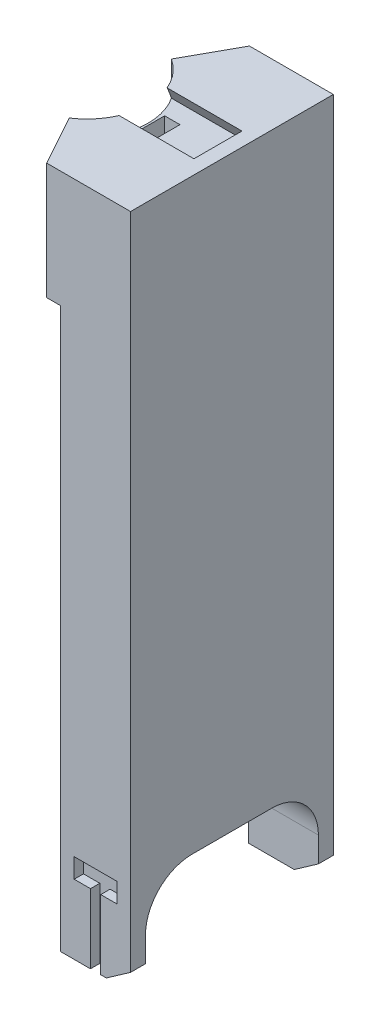
from build123d import *

# Parameters (mm, degrees)
SKETCH2_W               = 18
SKETCH2_H               = 43.5
BOSS_EXTRUDE1_DEPTH     = 25
CUT_EXTRUDE1_DEPTH      = 15
CUT_EXTRUDE1_DEPTH_BACK = 6.951267747
CUT_EXTRUDE2_START      = 0.4
CUT_EXTRUDE2_DEPTH      = 3.3
SKETCH5_W               = 15
SKETCH5_H               = 43.5
BOSS_EXTRUDE2_DEPTH     = 120
SKETCH6_W               = 2.2
SKETCH6_H               = 14.9
CUT_EXTRUDE3_DEPTH      = 2
CUT_EXTRUDE4_START      = -43.5
SKETCH6_3_W             = 2.2
SKETCH6_3_H             = 14.9
CUT_EXTRUDE4_DEPTH      = 2
CUT_EXTRUDE5_DEPTH      = 44.5
SKETCH8_W               = 37.1
SKETCH8_H               = 38
CUT_EXTRUDE6_DEPTH      = 16
FILLET1_R               = 10


with BuildPart() as part:
    # Sketch2 → Boss-Extrude1 (new body)
    with BuildSketch(Plane(origin=(0, 0, 0), x_dir=(1, 0, 0), z_dir=(0, 1, 0))):
        with BuildLine():
            Line((-9, 0), (-9, 21.75))
            Line((-9, 21.75), (-14.951267747, 10.950365309))
            ThreePointArc((-14.951267747, 10.950365309), (-10.583942354, 6.231534486), (-9, 0))
        make_face()
        with BuildLine():
            Line((-9, -21.75), (-9, 0))
            ThreePointArc((-9, 0), (-10.583942354, -6.231534486), (-14.951267747, -10.950365309))
            Line((-14.951267747, -10.950365309), (-9, -21.75))
        make_face()
        Rectangle(SKETCH2_W, SKETCH2_H)
    extrude(amount=BOSS_EXTRUDE1_DEPTH)

    # Sketch3 → Cut-Extrude1 (cut, two sides)
    with BuildSketch(Plane(origin=(-9, 0, 0), x_dir=(0, 0, -1), z_dir=(1, 0, 0))) as cut_extrude1_sk:
        Polygon((-5.15, 25), (5.15, 25), (7.15, 21.535898385), (-7.15, 21.535898385), align=None)
    extrude(amount=CUT_EXTRUDE1_DEPTH, mode=Mode.SUBTRACT)
    extrude(cut_extrude1_sk.sketch, amount=-CUT_EXTRUDE1_DEPTH_BACK, mode=Mode.SUBTRACT)

    # Sketch4 → Cut-Extrude2 (cut)
    with BuildSketch(Plane(origin=(-9, 0, 0), x_dir=(0, 0, -1), z_dir=(1, 0, 0)).offset(CUT_EXTRUDE2_START)):
        with BuildLine():
            Line((3.15, 29.404082691), (3.15, 4.535898385))
            ThreePointArc((3.15, 4.535898385), (0, 1.385898385), (-3.15, 4.535898385))
            Line((-3.15, 4.535898385), (-3.15, 29.404082691))
            ThreePointArc((-3.15, 29.404082691), (0, 32.554082691), (3.15, 29.404082691))
        make_face()
    extrude(amount=CUT_EXTRUDE2_DEPTH, mode=Mode.SUBTRACT)

    # Sketch5 → Boss-Extrude2 (add)
    with BuildSketch(Plane.XZ):
        with Locations((1.5, 0)):
            Rectangle(SKETCH5_W, SKETCH5_H)
    extrude(amount=BOSS_EXTRUDE2_DEPTH)

    # Sketch6 → Cut-Extrude3 (cut)
    with BuildSketch(Plane.XY.offset(21.75)):
        Polygon((-3.1, -105.1), (0.4, -105.1), (2.6, -105.1), (6.1, -105.1), (6.1, -100.9), (-3.1, -100.9), align=None)
        with Locations((1.5, -112.55)):
            Rectangle(SKETCH6_W, SKETCH6_H)
    extrude(amount=-CUT_EXTRUDE3_DEPTH, mode=Mode.SUBTRACT)

    # Sketch6_3 → Cut-Extrude4 (cut)
    with BuildSketch(Plane.XY.offset(21.75).offset(CUT_EXTRUDE4_START)):
        Polygon((-3.1, -105.1), (0.4, -105.1), (2.6, -105.1), (6.1, -105.1), (6.1, -100.9), (-3.1, -100.9), align=None)
        with Locations((1.5, -112.55)):
            Rectangle(SKETCH6_3_W, SKETCH6_3_H)
    extrude(amount=CUT_EXTRUDE4_DEPTH, mode=Mode.SUBTRACT)

    # Sketch7 → Cut-Extrude5 (cut, through all)
    with BuildSketch(Plane.XY.offset(21.75)):
        Polygon((9, -116.358920801), (3.8, -120), (9, -120), align=None)
    extrude(amount=-CUT_EXTRUDE5_DEPTH, mode=Mode.SUBTRACT)

    # Sketch8 → Cut-Extrude6 (cut, through all)
    with BuildSketch(Plane.ZY.offset(6)):
        with Locations((0, -120)):
            Rectangle(SKETCH8_W, SKETCH8_H)
    extrude(amount=-CUT_EXTRUDE6_DEPTH, mode=Mode.SUBTRACT)

    # Fillet1
    fillet1_edges = [part.edges().sort_by_distance(p)[0] for p in [
        (1.5, -101, 18.55),
        (1.5, -101, -18.55),
    ]]
    fillet(fillet1_edges, radius=FILLET1_R)


solid = part.part
